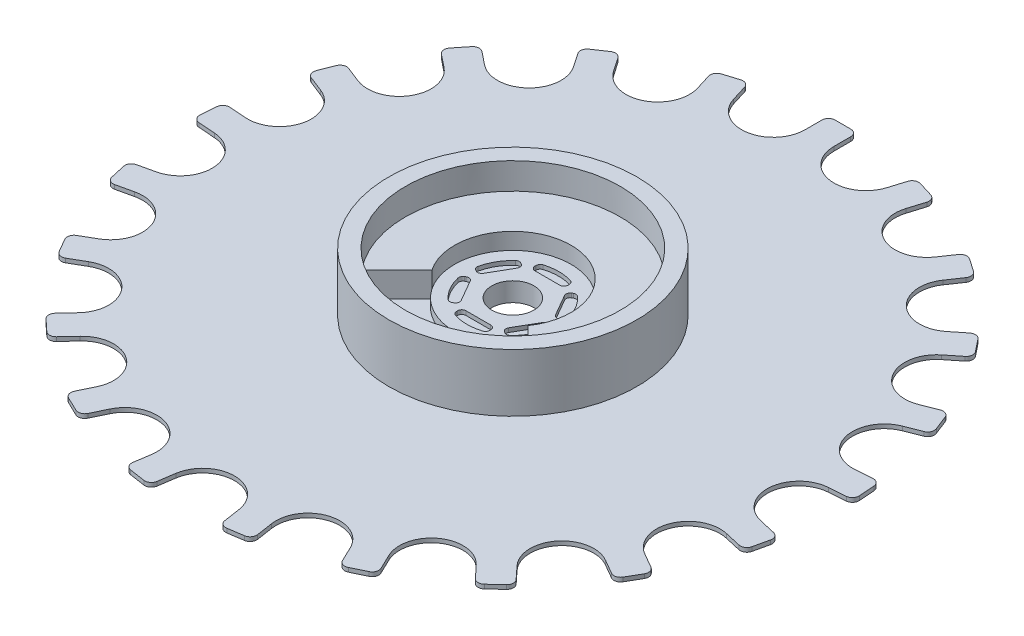
from build123d import *

# Parameters (mm, degrees)
RESSALTO_EXTRUS_O1_DEPTH = 0.25
ESBO_O2_R                = 1.745
RESSALTO_EXTRUS_O2_DEPTH = 4.625
PADR_OCIRCULAR1_COUNT    = 21
FILLET2_R                = 3.85
SKETCH2_R                = 15
BOSS_EXTRUDE1_DEPTH      = 7
SKETCH4_R                = 13
CUT_EXTRUDE2_DEPTH       = 6.2
SKETCH7_R                = 7.05
BOSS_EXTRUDE4_DEPTH      = 1
CUT_EXTRUDE3_DEPTH       = 0.5
BOSS_EXTRUDE5_DEPTH      = 3
SKETCH3_R                = 2.55
CUT_EXTRUDE1_DEPTH       = 8.25
CUT_EXTRUDE1_DEPTH_BACK  = 1.25


with BuildPart() as part:
    # Esboço1 → Ressalto-extrusão1 (new body, symmetric)
    with BuildSketch(Plane.XZ):
        with BuildLine():
            Line((-0.945, 0), (0.945, 0))
            ThreePointArc((0.945, 0), (1.510685425, -0.234314575), (1.745, -0.8))
            Line((1.745, -0.8), (1.745, -39.142))
            ThreePointArc((1.745, -39.142), (1.510685425, -39.707685425), (0.945, -39.942))
            Line((0.945, -39.942), (-0.945, -39.942))
            ThreePointArc((-0.945, -39.942), (-1.510685425, -39.707685425), (-1.745, -39.142))
            Line((-1.745, -39.142), (-1.745, -0.8))
            ThreePointArc((-1.745, -0.8), (-1.510685425, -0.234314575), (-0.945, 0))
        make_face()
    ressalto_extrus_o1 = extrude(amount=RESSALTO_EXTRUS_O1_DEPTH, both=True)

    # Esboço2 → Ressalto-extrusão2 (add)
    with BuildSketch(Plane(origin=(0, 0, 0), x_dir=(1, 0, 0), z_dir=(0, 1, 0))):
        Circle(ESBO_O2_R)
    extrude(amount=RESSALTO_EXTRUS_O2_DEPTH)

    # PadrãoCircular1: Ressalto-extrusão1 ×21 about axis
    padr_ocircular1_axis = Axis((0, 0, 0), (0, 1, 0))
    for i in range(1, PADR_OCIRCULAR1_COUNT):
        add(ressalto_extrus_o1.rotate(padr_ocircular1_axis, i * 360 / PADR_OCIRCULAR1_COUNT))

    # Fillet2
    fillet2_edges = [part.edges().sort_by_distance(p)[0] for p in [
        (-1.745, 0, -11.577318542),
        (1.745, 0, -11.577318542),
        (0, 0, 11.708088214),
        (7.963522415, 0, -8.582635981),
        (5.079949092, 0, -10.548622983),
        (-3.451019584, 0, 11.187930705),
        (-9.153751965, 0, 7.299873601),
        (-6.595400933, 0, 9.673676455),
        (-11.675350025, 0, 0.874946528),
        (-11.414541998, 0, -2.605294724),
        (-10.898751965, 0, 4.277444941),
        (10.139501823, 0, -5.854044107),
        (11.675350025, 0, 0.874946528),
        (11.414541998, 0, -2.605294724),
        (9.153751965, 0, 7.299873601),
        (6.595400933, 0, 9.673676455),
        (10.898751965, 0, 4.277444941),
        (3.451019584, 0, 11.187930705),
        (-5.079949092, 0, -10.548622983),
        (-10.139501823, 0, -5.854044107),
        (-7.963522415, 0, -8.582635981),
    ]]
    fillet(fillet2_edges, radius=FILLET2_R)

    # Sketch2 → Boss-Extrude1 (add)
    with BuildSketch(Plane(origin=(0, 0.25, 0), x_dir=(1, 0, 0), z_dir=(0, 1, 0))):
        Circle(SKETCH2_R)
    extrude(amount=BOSS_EXTRUDE1_DEPTH)

    # Sketch4 → Cut-Extrude2 (cut)
    with BuildSketch(Plane(origin=(0, 7.25, 0), x_dir=(1, 0, 0), z_dir=(0, 1, 0))):
        Circle(SKETCH4_R)
    extrude(amount=-CUT_EXTRUDE2_DEPTH, mode=Mode.SUBTRACT)

    # Sketch7 → Boss-Extrude4 (add)
    with BuildSketch(Plane(origin=(0, 1.05, 0), x_dir=(1, 0, 0), z_dir=(0, 1, 0))):
        Circle(SKETCH7_R)
    extrude(amount=BOSS_EXTRUDE4_DEPTH)

    # Sketch9 → Cut-Extrude3 (cut)
    with BuildSketch(Plane(origin=(0, 2.05, 0), x_dir=(1, 0, 0), z_dir=(0, 1, 0))):
        with BuildLine():
            Line((-2, -4.822084611), (-2, -4.677113095))
            ThreePointArc((-2, -4.677113095), (-1.853553391, -4.323559705), (-1.5, -4.177113095))
            Line((-1.5, -4.177113095), (1.5, -4.177113095))
            ThreePointArc((1.5, -4.177113095), (1.853553391, -4.323559705), (2, -4.677113095))
            Line((2, -4.677113095), (2, -4.822084611))
            ThreePointArc((2, -4.822084611), (1.902652099, -5.118515526), (1.648514851, -5.299518731))
            ThreePointArc((1.648514851, -5.299518731), (0, -5.55), (-1.648514851, -5.299518731))
            ThreePointArc((-1.648514851, -5.299518731), (-1.902652099, -5.118515526), (-2, -4.822084611))
        make_face()
        with BuildLine():
            Line((-5.176047773, -0.678991498), (-5.050498757, -0.60650574))
            ThreePointArc((-5.050498757, -0.60650574), (-4.671089234, -0.556555529), (-4.367486055, -0.789518442))
            Line((-4.367486055, -0.789518442), (-2.867486055, -3.387594653))
            ThreePointArc((-2.867486055, -3.387594653), (-2.817535844, -3.767004176), (-3.050498757, -4.070607355))
            Line((-3.050498757, -4.070607355), (-3.176047773, -4.143093113))
            ThreePointArc((-3.176047773, -4.143093113), (-3.481438426, -4.207002815), (-3.765260423, -4.077415106))
            ThreePointArc((-3.765260423, -4.077415106), (-4.806440991, -2.775), (-5.413775275, -1.222103626))
            ThreePointArc((-5.413775275, -1.222103626), (-5.384090525, -0.911512711), (-5.176047773, -0.678991498))
        make_face()
        with BuildLine():
            Line((-3.176047773, 4.143093113), (-3.050498757, 4.070607355))
            ThreePointArc((-3.050498757, 4.070607355), (-2.817535844, 3.767004176), (-2.867486055, 3.387594653))
            Line((-2.867486055, 3.387594653), (-4.367486055, 0.789518442))
            ThreePointArc((-4.367486055, 0.789518442), (-4.671089234, 0.556555529), (-5.050498757, 0.60650574))
            Line((-5.050498757, 0.60650574), (-5.176047773, 0.678991498))
            ThreePointArc((-5.176047773, 0.678991498), (-5.384090525, 0.911512711), (-5.413775275, 1.222103626))
            ThreePointArc((-5.413775275, 1.222103626), (-4.806440991, 2.775), (-3.765260423, 4.077415106))
            ThreePointArc((-3.765260423, 4.077415106), (-3.481438426, 4.207002815), (-3.176047773, 4.143093113))
        make_face()
        with BuildLine():
            Line((2, 4.822084611), (2, 4.677113095))
            ThreePointArc((2, 4.677113095), (1.853553391, 4.323559705), (1.5, 4.177113095))
            Line((1.5, 4.177113095), (-1.5, 4.177113095))
            ThreePointArc((-1.5, 4.177113095), (-1.853553391, 4.323559705), (-2, 4.677113095))
            Line((-2, 4.677113095), (-2, 4.822084611))
            ThreePointArc((-2, 4.822084611), (-1.902652099, 5.118515526), (-1.648514851, 5.299518731))
            ThreePointArc((-1.648514851, 5.299518731), (0, 5.55), (1.648514851, 5.299518731))
            ThreePointArc((1.648514851, 5.299518731), (1.902652099, 5.118515526), (2, 4.822084611))
        make_face()
        with BuildLine():
            Line((5.176047773, 0.678991498), (5.050498757, 0.60650574))
            ThreePointArc((5.050498757, 0.60650574), (4.671089234, 0.556555529), (4.367486055, 0.789518442))
            Line((4.367486055, 0.789518442), (2.867486055, 3.387594653))
            ThreePointArc((2.867486055, 3.387594653), (2.817535844, 3.767004176), (3.050498757, 4.070607355))
            Line((3.050498757, 4.070607355), (3.176047773, 4.143093113))
            ThreePointArc((3.176047773, 4.143093113), (3.481438426, 4.207002815), (3.765260423, 4.077415106))
            ThreePointArc((3.765260423, 4.077415106), (4.806440991, 2.775), (5.413775275, 1.222103626))
            ThreePointArc((5.413775275, 1.222103626), (5.384090525, 0.911512711), (5.176047773, 0.678991498))
        make_face()
        with BuildLine():
            Line((3.176047773, -4.143093113), (3.050498757, -4.070607355))
            ThreePointArc((3.050498757, -4.070607355), (2.817535844, -3.767004176), (2.867486055, -3.387594653))
            Line((2.867486055, -3.387594653), (4.367486055, -0.789518442))
            ThreePointArc((4.367486055, -0.789518442), (4.671089234, -0.556555529), (5.050498757, -0.60650574))
            Line((5.050498757, -0.60650574), (5.176047773, -0.678991498))
            ThreePointArc((5.176047773, -0.678991498), (5.384090525, -0.911512711), (5.413775275, -1.222103626))
            ThreePointArc((5.413775275, -1.222103626), (4.806440991, -2.775), (3.765260423, -4.077415106))
            ThreePointArc((3.765260423, -4.077415106), (3.481438426, -4.207002815), (3.176047773, -4.143093113))
        make_face()
    extrude(amount=-CUT_EXTRUDE3_DEPTH, mode=Mode.SUBTRACT)

    # Sketch8 → Boss-Extrude5 (add)
    with BuildSketch(Plane(origin=(0, 1.05, 0), x_dir=(1, 0, 0), z_dir=(0, 1, 0))):
        with BuildLine():
            Line((-10.050651278, -8.245265847), (-5.805385431, -4))
            ThreePointArc((-5.805385431, -4), (0, 7.05), (5.805385431, -4))
            Line((5.805385431, -4), (10.050651278, -8.245265847))
            ThreePointArc((10.050651278, -8.245265847), (0, 13), (-10.050651278, -8.245265847))
        make_face()
    extrude(amount=BOSS_EXTRUDE5_DEPTH)

    # Sketch3 → Cut-Extrude1 (cut, two sides)
    with BuildSketch(Plane(origin=(0, 0, 0), x_dir=(1, 0, 0), z_dir=(0, 1, 0))) as cut_extrude1_sk:
        Circle(SKETCH3_R)
    extrude(amount=CUT_EXTRUDE1_DEPTH, mode=Mode.SUBTRACT)
    extrude(cut_extrude1_sk.sketch, amount=-CUT_EXTRUDE1_DEPTH_BACK, mode=Mode.SUBTRACT)


solid = part.part
